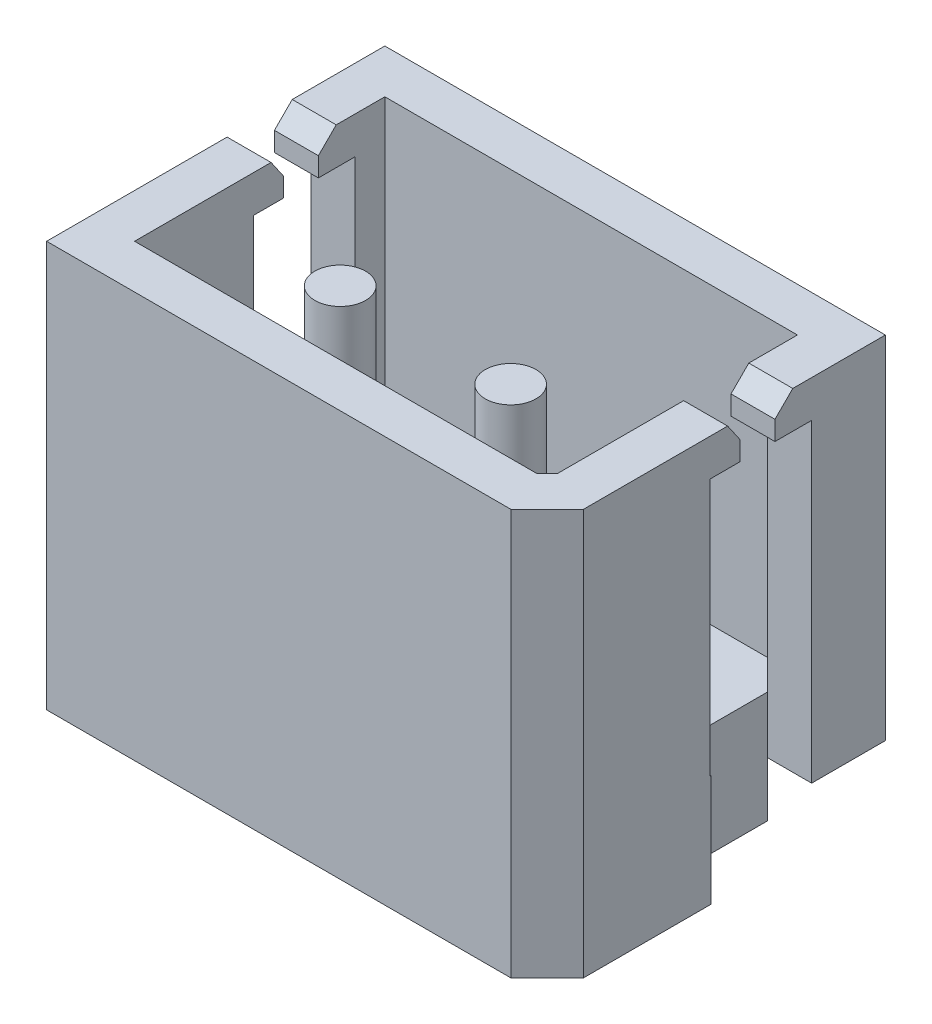
from build123d import *

# Parameters (mm, degrees)
SKETCH1_R                  = 0.375
BOSS_EXTRUDE1_DEPTH        = 5.7
BOSS_EXTRUDE1_DEPTH_BACK   = 1
BOSS_EXTRUDE1_2_DEPTH      = 5.7
BOSS_EXTRUDE1_2_DEPTH_BACK = 1
BOSS_EXTRUDE2_DEPTH        = 1.65
BOSS_EXTRUDE4_DEPTH        = 6
SKETCH5_W                  = 8.470715742
SKETCH5_H                  = 1.5
CUT_EXTRUDE1_DEPTH         = 4.35
BOSS_EXTRUDE5_DEPTH        = 0.65
BOSS_EXTRUDE6_DEPTH        = 0.65
SKETCH8_W                  = 1.741902436
SKETCH8_H                  = 1.335943606
CUT_EXTRUDE2_DEPTH         = 4.7
CUT_EXTRUDE2_DEPTH_BACK    = 4.7
SKETCH10_W                 = 0.65
SKETCH10_H                 = 1.488696467
SKETCH10_H_2               = 1.5
CUT_EXTRUDE3_DEPTH         = 10


with BuildPart() as part:
    # Sketch1 → Boss-Extrude1 (new body, two sides)
    with BuildSketch(Plane(origin=(0, 0, 0), x_dir=(1, 0, 0), z_dir=(0, 1, 0))) as boss_extrude1_sk:
        with Locations((-1.26, 0)):
            Circle(SKETCH1_R)
    extrude(amount=BOSS_EXTRUDE1_DEPTH)
    extrude(boss_extrude1_sk.sketch, amount=-BOSS_EXTRUDE1_DEPTH_BACK)



with BuildPart() as body_2:
    # Sketch1 → Boss-Extrude1 2 (new body, two sides)
    with BuildSketch(Plane(origin=(0, 0, 0), x_dir=(1, 0, 0), z_dir=(0, 1, 0))) as boss_extrude1_2_sk:
        with Locations((1.26, 0)):
            Circle(SKETCH1_R)
    extrude(amount=BOSS_EXTRUDE1_2_DEPTH)
    extrude(boss_extrude1_2_sk.sketch, amount=-BOSS_EXTRUDE1_2_DEPTH_BACK)


with BuildPart() as part_1:
    add(part.part)

    add(body_2.part)  # Boss-Extrude2 merges body 2
    # Sketch2 → Boss-Extrude2 (add)
    with BuildSketch(Plane(origin=(0, 0, 0), x_dir=(1, 0, 0), z_dir=(0, 1, 0))):
        Polygon((3.7, -1.365567335), (3.165567335, -1.9), (-3.7, -1.9), (-3.7, 3.1), (3.7, 3.1), align=None)
    extrude(amount=BOSS_EXTRUDE2_DEPTH)

    # Sketch4 → Boss-Extrude4 (add)
    with BuildSketch(Plane(origin=(0, 0, 0), x_dir=(1, 0, 0), z_dir=(0, 1, 0))):
        Polygon((3.165567335, -1.9), (3.7, -1.365567335), (3.7, 3.1), (-3.7, 3.1), (-3.7, -1.9), align=None)
        Polygon((-3.05, -1.25), (2.89632852, -1.25), (3.05, -1.09632852), (3.05, 2.45), (-3.05, 2.45), align=None, mode=Mode.SUBTRACT)
    extrude(amount=BOSS_EXTRUDE4_DEPTH)

    # Sketch5 → Cut-Extrude1 (cut)
    with BuildSketch(Plane(origin=(0, 6, 0), x_dir=(1, 0, 0), z_dir=(0, 1, 0))):
        with Locations((0, 1.259795506)):
            Rectangle(SKETCH5_W, SKETCH5_H)
    extrude(amount=-CUT_EXTRUDE1_DEPTH, mode=Mode.SUBTRACT)

    # Sketch6 → Boss-Extrude5 (add)
    with BuildSketch(Plane.ZY.offset(3.7)):
        Polygon((-2.009795506, 6), (-1.731148103, 6), (-1.467778214, 5.736630111), (-1.467778214, 5.451734295), (-2.009795506, 5.451734295), align=None)
        Polygon((-0.509795506, 6), (-0.768050416, 6), (-0.950007845, 5.736630111), (-0.950007845, 5.451734295), (-0.509795506, 5.451734295), align=None)
    extrude(amount=-BOSS_EXTRUDE5_DEPTH)

    # Sketch7 → Boss-Extrude6 (add)
    with BuildSketch(Plane(origin=(3.7, 0, 0), x_dir=(0, 0, -1), z_dir=(1, 0, 0))):
        Polygon((0.768050416, 6), (0.509795506, 6), (0.509795506, 5.451734295), (0.950007845, 5.451734295), (0.950007845, 5.736630111), align=None)
        Polygon((2.009795506, 6), (1.731148103, 6), (1.467778214, 5.736630111), (1.467778214, 5.451734295), (2.009795506, 5.451734295), align=None)
    extrude(amount=-BOSS_EXTRUDE6_DEPTH)

    # Sketch8 → Cut-Extrude2 (cut, two sides)
    with BuildSketch(Plane(origin=(0, 0, 0), x_dir=(0, 0, -1), z_dir=(1, 0, 0))) as cut_extrude2_sk:
        with Locations((2.880746724, 0.138578557)):
            Rectangle(SKETCH8_W, SKETCH8_H)
    extrude(amount=CUT_EXTRUDE2_DEPTH, mode=Mode.SUBTRACT)
    extrude(cut_extrude2_sk.sketch, amount=-CUT_EXTRUDE2_DEPTH_BACK, mode=Mode.SUBTRACT)

    # Sketch10 → Cut-Extrude3 (cut)
    with BuildSketch(Plane(origin=(0, 1.65, 0), x_dir=(1, 0, 0), z_dir=(0, 1, 0))):
        with Locations((3.375, 1.265447273)):
            Rectangle(SKETCH10_W, SKETCH10_H)
        with Locations((-3.375, 1.259795506)):
            Rectangle(SKETCH10_W, SKETCH10_H_2)
    extrude(amount=-CUT_EXTRUDE3_DEPTH, mode=Mode.SUBTRACT)


solid = part_1.part
